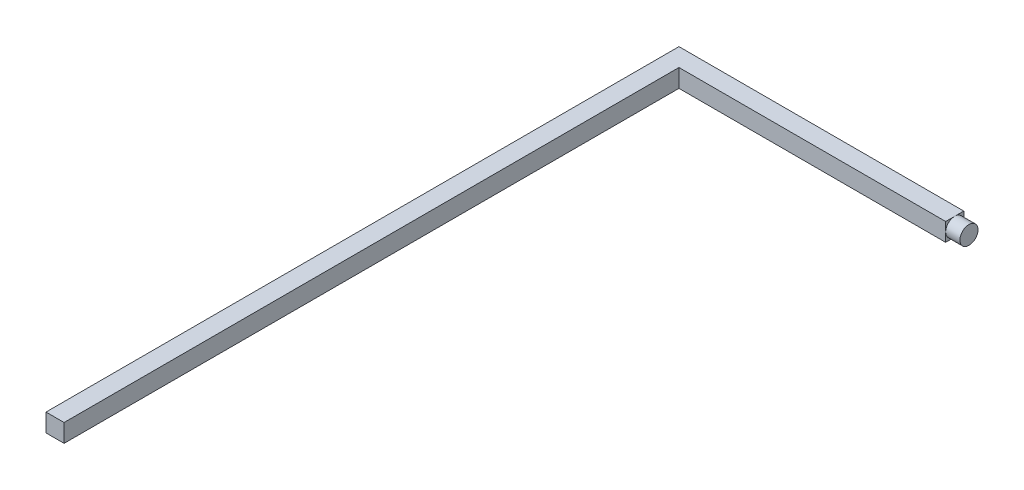
from build123d import *

# Parameters (mm, degrees)
SKETCH1_W           = 18.73
SKETCH1_H           = 1.27
SKETCH1_W_2         = 1.27
SKETCH1_H_2         = 43.18
BOSS_EXTRUDE1_DEPTH = 0.635
SKETCH2_R           = 0.635
BOSS_EXTRUDE2_DEPTH = 1


with BuildPart() as part:
    # Sketch1 → Boss-Extrude1 (new body, symmetric)
    with BuildSketch(Plane(origin=(0, 0, 0), x_dir=(1, 0, 0), z_dir=(0, 1, 0))):
        with Locations((10, 21.59)):
            Rectangle(SKETCH1_W, SKETCH1_H)
        with Locations((0, 21.59)):
            Rectangle(SKETCH1_W_2, SKETCH1_H)
        with Locations((0, -0.635)):
            Rectangle(SKETCH1_W_2, SKETCH1_H_2)
    extrude(amount=BOSS_EXTRUDE1_DEPTH, both=True)

    # Sketch2 → Boss-Extrude2 (add)
    with BuildSketch(Plane(origin=(19.365, 0, 0), x_dir=(0, 0, -1), z_dir=(1, 0, 0))):
        with Locations((21.59, 0)):
            Circle(SKETCH2_R)
    extrude(amount=BOSS_EXTRUDE2_DEPTH)


solid = part.part
